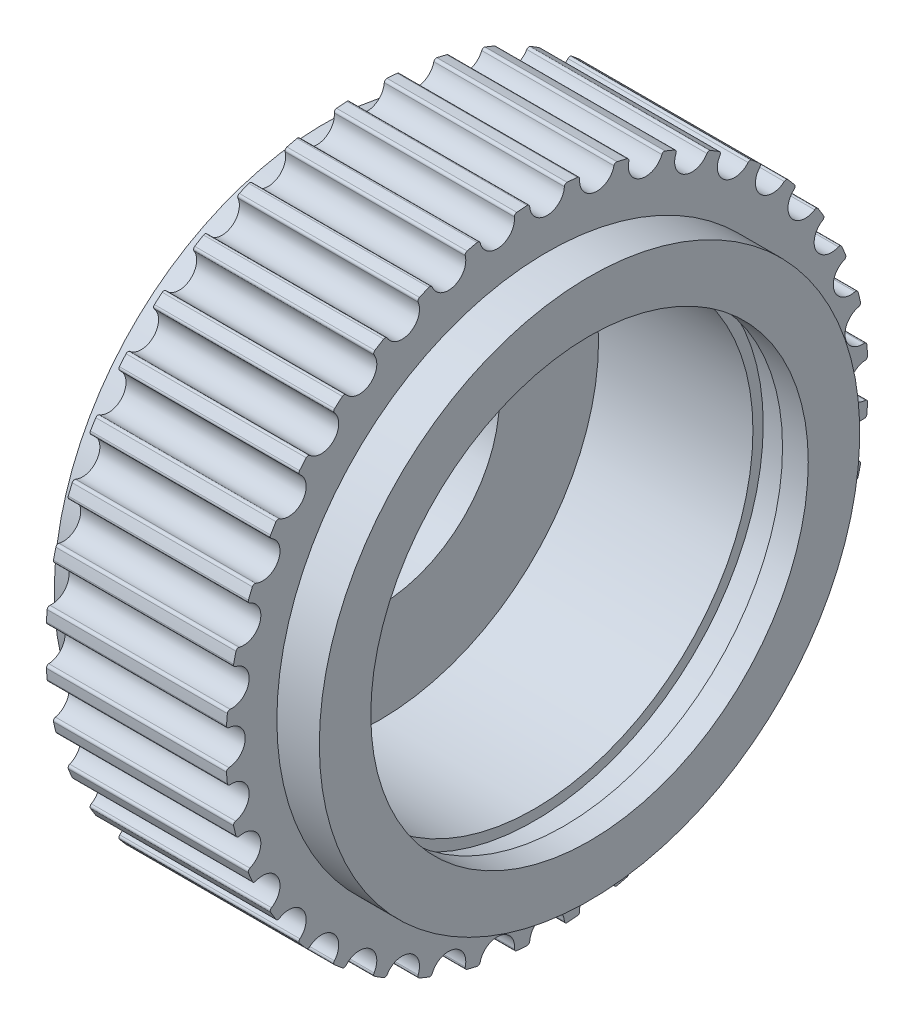
from build123d import *

# Parameters (mm, degrees)
CUT_EXTRUDE2_DEPTH       = 11.3
FILLET3_R                = 0.1
CIRPATTERN2_COUNT        = 40
FILLET3_OF_CIRPATTERN2_R = 0.1


with BuildPart() as part:
    # Sketch1 → Revolve1 (revolve)
    with BuildSketch(Plane.XY):
        Polygon((0, 0), (10.3, 0), (10.3, 10.5), (8.65, 10.5), (8.65, 12.48), (1.65, 12.48), (1.65, 10.5), (0, 10.5), align=None)
    revolve(axis=Axis((0, 0, 0), (1, 0, 0)))

    # Sketch2 → Cut-Revolve1 (revolve, cut)
    with BuildSketch(Plane.XY):
        Polygon((0, 4.65), (2.15, 4.65), (2.15, 8.5), (8.15, 8.5), (8.15, 8.9), (9.3, 8.9), (9.3, 8.5), (10.3, 8.5), (10.3, 0), (0, 0), align=None)
    revolve(axis=Axis((0, 0, 0), (1, 0, 0)), mode=Mode.SUBTRACT)

    # Sketch5 → Cut-Extrude2 (cut, through all)
    with BuildSketch(Plane.ZY):
        with BuildLine():
            ThreePointArc((-0.672600696, 12.461862152), (0, 11.73), (0.672600696, 12.461862152))
            ThreePointArc((0.672600696, 12.461862152), (0, 12.48), (-0.672600696, 12.461862152))
        make_face()
    cut_extrude2 = extrude(amount=-CUT_EXTRUDE2_DEPTH, mode=Mode.SUBTRACT)

    # Fillet3
    fillet3_edges = [part.edges().sort_by_distance(p)[0] for p in [
        (5.15, 12.461862152, -0.672600696),
        (5.15, 12.461862152, 0.672600696),
    ]]
    fillet(fillet3_edges, radius=FILLET3_R)

    # CirPattern2: Cut-Extrude2 ×40 about axis
    cirpattern2_axis = Axis((0, 0, 0), (1, 0, 0))
    for i in range(1, CIRPATTERN2_COUNT):
        add(cut_extrude2.rotate(cirpattern2_axis, i * 360 / CIRPATTERN2_COUNT), mode=Mode.SUBTRACT)

    # Fillet3 of CirPattern2
    fillet3_of_cirpattern2_edges = [part.edges().sort_by_distance(p)[0] for p in [
        (5.15, 12.41365388, 1.285144874),
        (5.15, 12.20321802, 2.613784604),
        (5.15, 12.059780251, 3.211245912),
        (5.15, 11.64409016, 4.490608461),
        (5.15, 11.408954807, 5.058275418),
        (5.15, 10.798246155, 6.256858634),
        (5.15, 10.477203032, 6.780753396),
        (5.15, 9.686513493, 7.869044182),
        (5.15, 9.287467747, 8.336266721),
        (5.15, 8.336266721, 9.287467747),
        (5.15, 7.869044182, 9.686513493),
        (5.15, 6.780753396, 10.477203032),
        (5.15, 6.256858634, 10.798246155),
        (5.15, 5.058275418, 11.408954807),
        (5.15, 4.490608461, 11.64409016),
        (5.15, 3.211245912, 12.059780251),
        (5.15, 2.613784604, 12.20321802),
        (5.15, 1.285144874, 12.41365388),
        (5.15, 0.672600696, 12.461862152),
        (5.15, -0.672600696, 12.461862152),
        (5.15, -1.285144874, 12.41365388),
        (5.15, -2.613784604, 12.20321802),
        (5.15, -3.211245912, 12.059780251),
        (5.15, -4.490608461, 11.64409016),
        (5.15, -5.058275418, 11.408954807),
        (5.15, -6.256858634, 10.798246155),
        (5.15, -6.780753396, 10.477203032),
        (5.15, -7.869044182, 9.686513493),
        (5.15, -8.336266721, 9.287467747),
        (5.15, -9.287467747, 8.336266721),
        (5.15, -9.686513493, 7.869044182),
        (5.15, -10.477203032, 6.780753396),
        (5.15, -10.798246155, 6.256858634),
        (5.15, -11.408954807, 5.058275418),
        (5.15, -11.64409016, 4.490608461),
        (5.15, -12.059780251, 3.211245912),
        (5.15, -12.20321802, 2.613784604),
        (5.15, -12.41365388, 1.285144874),
        (5.15, -12.461862152, 0.672600696),
        (5.15, -12.461862152, -0.672600696),
        (5.15, -12.41365388, -1.285144874),
        (5.15, -12.20321802, -2.613784604),
        (5.15, -12.059780251, -3.211245912),
        (5.15, -11.64409016, -4.490608461),
        (5.15, -11.408954807, -5.058275418),
        (5.15, -10.798246155, -6.256858634),
        (5.15, -10.477203032, -6.780753396),
        (5.15, -9.686513493, -7.869044182),
        (5.15, -9.287467747, -8.336266721),
        (5.15, -8.336266721, -9.287467747),
        (5.15, -7.869044182, -9.686513493),
        (5.15, -6.780753396, -10.477203032),
        (5.15, -6.256858634, -10.798246155),
        (5.15, -5.058275418, -11.408954807),
        (5.15, -4.490608461, -11.64409016),
        (5.15, -3.211245912, -12.059780251),
        (5.15, -2.613784604, -12.20321802),
        (5.15, -1.285144874, -12.41365388),
        (5.15, -0.672600696, -12.461862152),
        (5.15, 0.672600696, -12.461862152),
        (5.15, 1.285144874, -12.41365388),
        (5.15, 2.613784604, -12.20321802),
        (5.15, 3.211245912, -12.059780251),
        (5.15, 4.490608461, -11.64409016),
        (5.15, 5.058275418, -11.408954807),
        (5.15, 6.256858634, -10.798246155),
        (5.15, 6.780753396, -10.477203032),
        (5.15, 7.869044182, -9.686513493),
        (5.15, 8.336266721, -9.287467747),
        (5.15, 9.287467747, -8.336266721),
        (5.15, 9.686513493, -7.869044182),
        (5.15, 10.477203032, -6.780753396),
        (5.15, 10.798246155, -6.256858634),
        (5.15, 11.408954807, -5.058275418),
        (5.15, 11.64409016, -4.490608461),
        (5.15, 12.059780251, -3.211245912),
        (5.15, 12.20321802, -2.613784604),
        (5.15, 12.41365388, -1.285144874),
    ]]
    fillet(fillet3_of_cirpattern2_edges, radius=FILLET3_OF_CIRPATTERN2_R)


solid = part.part
